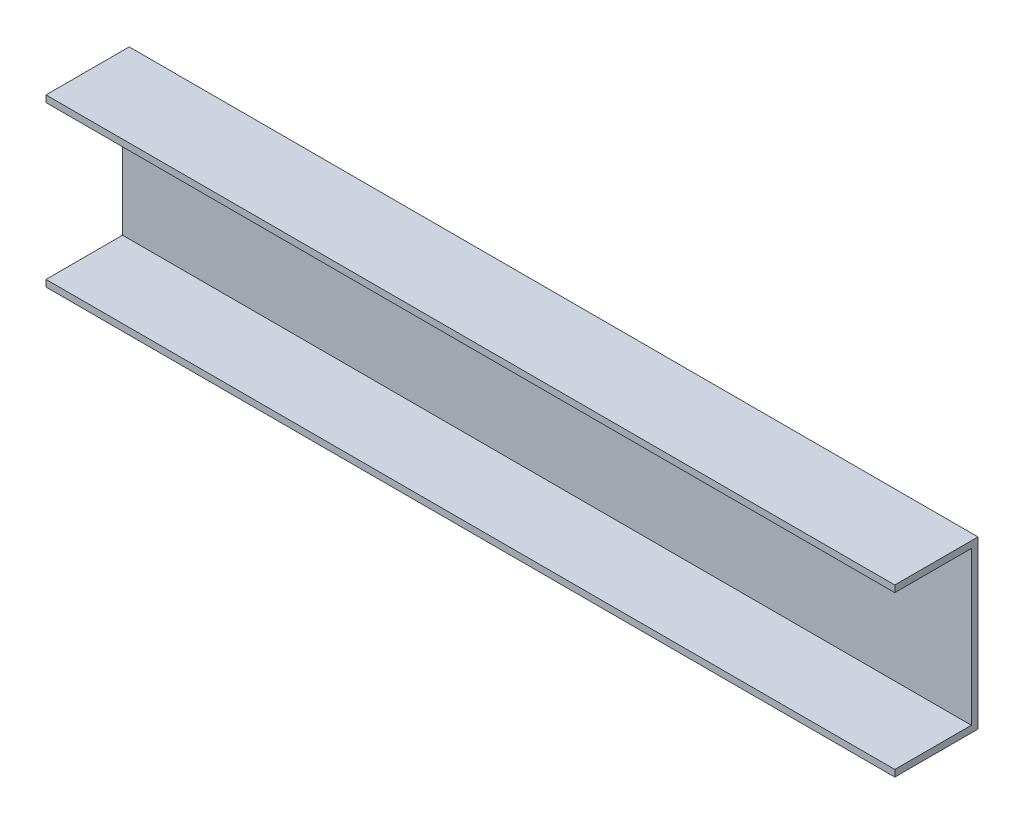
from build123d import *

# Parameters (mm, degrees)
BOSS_EXTRUDE1_DEPTH = 175
SKETCH2_R           = 2.55
CUT_EXTRUDE1_DEPTH  = 380
BOSS_EXTRUDE2_DEPTH = 80


with BuildPart() as part:
    # Sketch1 → Boss-Extrude1 (new body)
    with BuildSketch(Plane(origin=(0, 0, 0), x_dir=(0, 0, -1), z_dir=(1, 0, 0))):
        Polygon((0, 24.377952756), (23, 24.377952756), (23, -21.622047244), (0, -21.622047244), (0, -23.622047244), (25, -23.622047244), (25, 26.377952756), (0, 26.377952756), align=None)
    extrude(amount=BOSS_EXTRUDE1_DEPTH)

    # Sketch2 → Cut-Extrude1 (cut)
    with BuildSketch(Plane(origin=(0, 0, -25), x_dir=(-1, 0, 0), z_dir=(0, 0, -1))):
        with Locations((-30, 6.377952756)):
            Circle(SKETCH2_R)
    extrude(amount=-CUT_EXTRUDE1_DEPTH, mode=Mode.SUBTRACT)

    # Sketch3 → Boss-Extrude2 (add)
    with BuildSketch(Plane.ZY):
        Polygon((0, 26.377952756), (-25, 26.377952756), (-25, -23.622047244), (0, -23.622047244), (0, -21.622047244), (-23, -21.622047244), (-23, 24.377952756), (0, 24.377952756), align=None)
    extrude(amount=BOSS_EXTRUDE2_DEPTH)


solid = part.part
